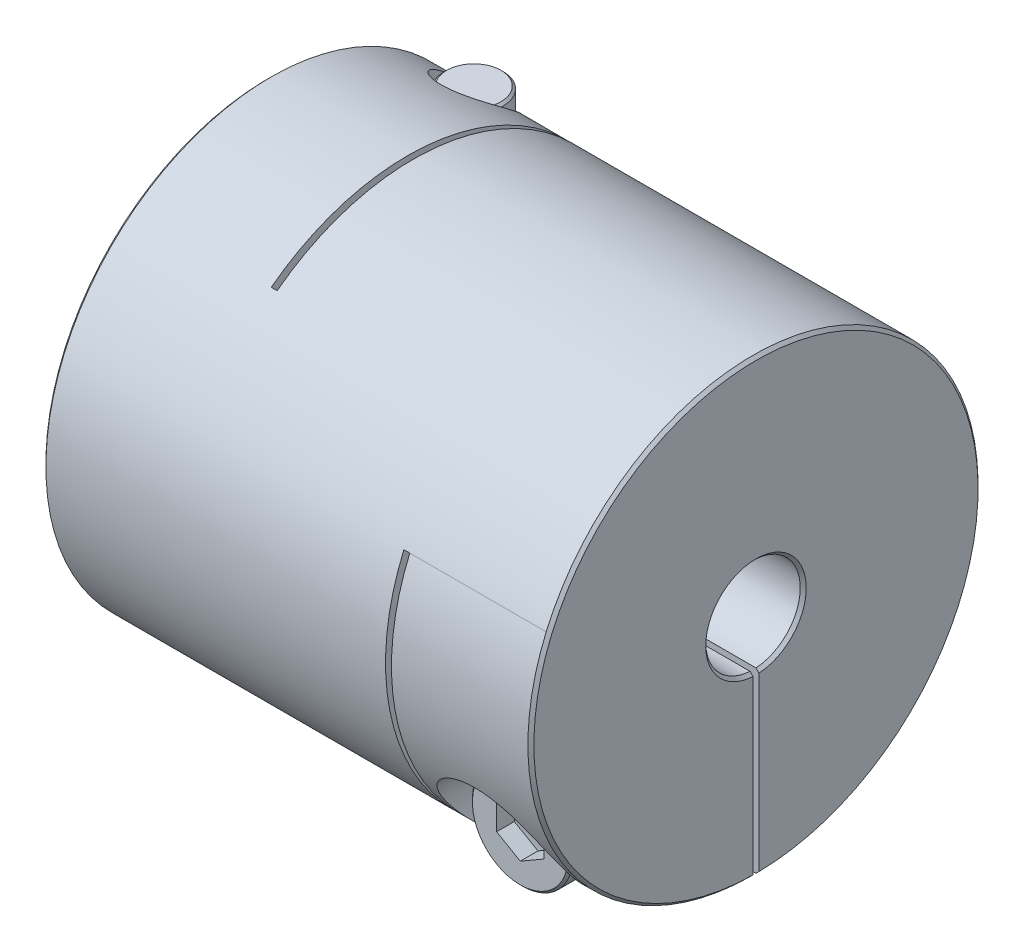
from build123d import *

# Parameters (mm, degrees)
SKETCH1_R                      = 19.05
BOSS_EXTRUDE1_DEPTH            = 20.65
SKETCH2_R                      = 4
CUT_EXTRUDE1_DEPTH             = 42.3
CHAMFER1_SIZE                  = 0.254
SKETCH4_W                      = 0.5
SKETCH4_H                      = 30.575
CUT_EXTRUDE2_DEPTH             = 39.1
SKETCH7_W                      = 0.5
SKETCH7_H                      = 26.575
CUT_EXTRUDE3_DEPTH             = 39.1
SKETCH8_W                      = 11.8
SKETCH8_H                      = 19.05
CUT_EXTRUDE5_DEPTH             = 0.25
SKETCH13_W                     = 11.8
SKETCH13_H                     = 19.05
CUT_EXTRUDE6_DEPTH             = 0.25
CBORE_FOR_M5_SHCS1_D           = 5.5
CBORE_FOR_M5_SHCS1_CBORE_D     = 10
CBORE_FOR_M5_SHCS1_CBORE_DEPTH = 10
CBORE_FOR_M5_SHCS2_D           = 5.5
CBORE_FOR_M5_SHCS2_CBORE_D     = 10
CBORE_FOR_M5_SHCS2_CBORE_DEPTH = 10
SKETCH16_R                     = 4.25
BOSS_EXTRUDE2_DEPTH            = 5
SKETCH17_R                     = 2.5
BOSS_EXTRUDE3_DEPTH            = 24.5
CHAMFER2_SIZE                  = 0.2
CUT_EXTRUDE7_DEPTH             = 1.5
CIRPATTERN1_COUNT              = 2
CIRPATTERN1_ANGLE              = 90


with BuildPart() as part:
    # Sketch1 → Boss-Extrude1 (new body, symmetric)
    with BuildSketch(Plane(origin=(0, 0, 0), x_dir=(0, 0, -1), z_dir=(1, 0, 0))):
        Circle(SKETCH1_R)
    extrude(amount=BOSS_EXTRUDE1_DEPTH, both=True)

    # Sketch2 → Cut-Extrude1 (cut, through all)
    with BuildSketch(Plane(origin=(20.65, 0, 0), x_dir=(0, 0, -1), z_dir=(1, 0, 0))):
        Circle(SKETCH2_R)
    extrude(amount=-CUT_EXTRUDE1_DEPTH, mode=Mode.SUBTRACT)

    # Chamfer1
    chamfer1_edges = [part.edges().sort_by_distance(p)[0] for p in [
        (-20.65, 0, 19.05),
        (20.65, 0, 19.05),
        (-20.65, 0, 4),
        (20.65, 0, 4),
    ]]
    chamfer(chamfer1_edges, length=CHAMFER1_SIZE)

    # Sketch4 → Cut-Extrude2 (cut, through all)
    with BuildSketch(Plane.XZ.offset(19.05)):
        with Locations((-8.6, -3.7625)):
            Rectangle(SKETCH4_W, SKETCH4_H)
    extrude(amount=-CUT_EXTRUDE2_DEPTH, mode=Mode.SUBTRACT)

    # Sketch7 → Cut-Extrude3 (cut, through all)
    with BuildSketch(Plane(origin=(0, 0, -19.05), x_dir=(-1, 0, 0), z_dir=(0, 0, -1))):
        with Locations((-8.6, -5.7625)):
            Rectangle(SKETCH7_W, SKETCH7_H)
    extrude(amount=-CUT_EXTRUDE3_DEPTH, mode=Mode.SUBTRACT)

    # Sketch8 → Cut-Extrude5 (cut, symmetric)
    with BuildSketch(Plane(origin=(0, 0, 0), x_dir=(1, 0, 0), z_dir=(0, 1, 0))):
        with Locations((-14.75, 9.525)):
            Rectangle(SKETCH8_W, SKETCH8_H)
    extrude(amount=CUT_EXTRUDE5_DEPTH, both=True, mode=Mode.SUBTRACT)

    # Sketch13 → Cut-Extrude6 (cut, symmetric)
    with BuildSketch(Plane.XY):
        with Locations((14.75, -9.525)):
            Rectangle(SKETCH13_W, SKETCH13_H)
    extrude(amount=CUT_EXTRUDE6_DEPTH, both=True, mode=Mode.SUBTRACT)

    # CBORE for M5 SHCS1 (through all)
    with Locations(Plane.XZ.offset(19.05)):
        with Locations((-14.75, -11.520269683)):
            CounterBoreHole(CBORE_FOR_M5_SHCS1_D / 2, CBORE_FOR_M5_SHCS1_CBORE_D / 2, CBORE_FOR_M5_SHCS1_CBORE_DEPTH)

    # CBORE for M5 SHCS2 (through all)
    with Locations(Plane.XY.offset(19.05)):
        with Locations((14.75, -11.520269683)):
            CounterBoreHole(CBORE_FOR_M5_SHCS2_D / 2, CBORE_FOR_M5_SHCS2_CBORE_D / 2, CBORE_FOR_M5_SHCS2_CBORE_DEPTH)


with BuildPart() as body_2:
    # Sketch16 → Boss-Extrude2 (new body)
    with BuildSketch(Plane.XY.offset(9.05)):
        with Locations((14.75, -11.520269683)):
            Circle(SKETCH16_R)
    extrude(amount=BOSS_EXTRUDE2_DEPTH)

    # Sketch17 → Boss-Extrude3 (add)
    with BuildSketch(Plane(origin=(0, 0, 9.05), x_dir=(-1, 0, 0), z_dir=(0, 0, -1))):
        with Locations(Location((-14.75, -11.520269683, 0), (0, 0, 180))):  # turned: the seam where the file's is
            Circle(SKETCH17_R)
    extrude(amount=BOSS_EXTRUDE3_DEPTH)

    # Chamfer2
    chamfer2_edges = [body_2.edges().sort_by_distance(p)[0] for p in [
        (10.5, -11.520269683, 9.05),
        (10.5, -11.520269683, 14.05),
        (12.25, -11.520269683, -15.45),
    ]]
    chamfer(chamfer2_edges, length=CHAMFER2_SIZE)

    # Sketch18 → Cut-Extrude7 (cut)
    with BuildSketch(Plane.XY.offset(14.05)):
        Polygon((14.75, -13.829670759), (16.75, -12.674970221), (16.75, -10.365569144), (14.75, -9.210868606), (12.75, -10.365569144), (12.75, -12.674970221), align=None)
    extrude(amount=-CUT_EXTRUDE7_DEPTH, mode=Mode.SUBTRACT)


with BuildPart() as body_3:
    # Mirror1: mirrored copy
    add(body_2.part.mirror(Plane(origin=(0, 0, 0), x_dir=(0, 0, 1), z_dir=(1, 0, 0))))


with BuildPart() as cirpattern1_1:
    # CirPattern1: pattern copy
    add(body_3.part.rotate(Axis((0, 0, 0), (1, 0, 0)), 1 * CIRPATTERN1_ANGLE / (CIRPATTERN1_COUNT - 1)))


solid = Compound([part.part, body_2.part, cirpattern1_1.part])
